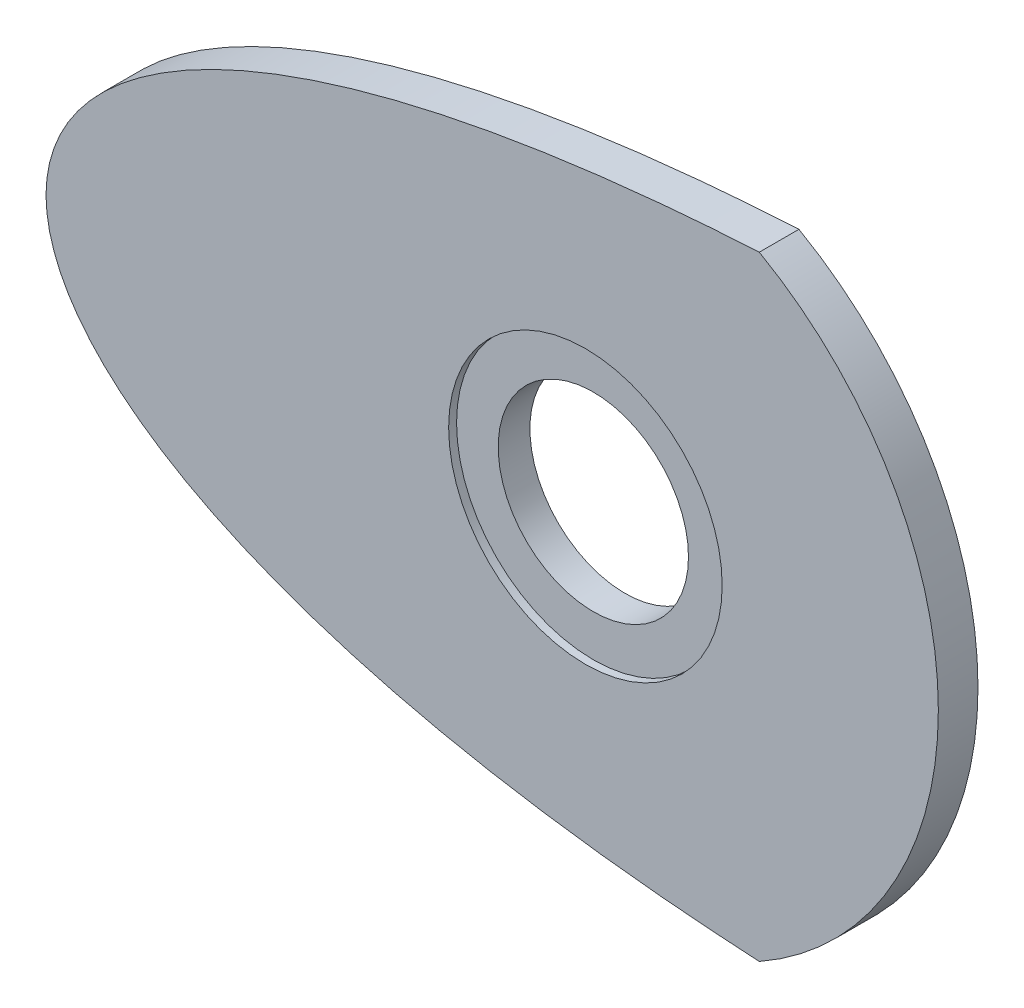
from build123d import *

# Parameters (mm, degrees)
BOSS_EXTRUDE2_DEPTH = 2.54
SKETCH1_5_R         = 4.233333332
BOSS_EXTRUDE3_DEPTH = 7.62
SKETCH1_6_R         = 6.096
CUT_EXTRUDE1_DEPTH  = 179.814895395
SKETCH4_R           = 8.763
CUT_EXTRUDE2_DEPTH  = 0.508


with BuildPart() as part:
    # Sketch1 → Boss-Extrude2 (new body)
    with BuildSketch(Plane.XY):
        with BuildLine():
            ThreePointArc((-126.772670279, 7.21547203), (-115.299991188, 26.89475243), (-126.772670279, 46.57403283))
            add(Edge.make_bspline(
                [(-172.474815081, 26.89475243), (-172.473819891, 27.230973869), (-172.419747256, 28.067223274), (-172.09778315, 29.537851691), (-171.305841422, 31.369969831), (-169.889362805, 33.399100842), (-167.799877065, 35.466403756), (-165.058549528, 37.462309128), (-161.711634876, 39.321499724), (-157.809164116, 41.006194136), (-153.398533523, 42.494070588), (-148.523738699, 43.77188575), (-143.225981342, 44.832188047), (-137.544438785, 45.671493001), (-132.01714462, 46.238870937), (-128.386674126, 46.485977046), (-126.772670279, 46.57403283)],
                knots=[0.5, 0.5, 0.5, 0.5, 0.502166769, 0.505390167, 0.509655974, 0.514947682, 0.521244711, 0.528520886, 0.536744945, 0.54588136, 0.555890751, 0.566730119, 0.57835299, 0.590709588, 0.603747039, 0.614168613, 0.614168613, 0.614168613, 0.614168613], degree=3))
            add(Edge.make_bspline(
                [(-172.474815081, 26.89475243), (-172.473819891, 26.558530991), (-172.419747256, 25.722281586), (-172.09778315, 24.251653169), (-171.305841422, 22.419535029), (-169.889362805, 20.390404018), (-167.799877065, 18.323101104), (-165.058549527, 16.327195732), (-161.711634875, 14.468005136), (-157.809164116, 12.783310723), (-153.398533522, 11.295434272), (-148.523738698, 10.01761911), (-143.225981341, 8.957316813), (-137.544438784, 8.118011859), (-132.01714462, 7.550633923), (-128.386674126, 7.303527814), (-126.772670279, 7.21547203)],
                knots=[0.5, 0.5, 0.5, 0.5, 0.502166769, 0.505390167, 0.509655974, 0.514947682, 0.521244711, 0.528520886, 0.536744945, 0.54588136, 0.555890751, 0.566730119, 0.57835299, 0.590709588, 0.603747039, 0.614168613, 0.614168613, 0.614168613, 0.614168613], degree=3))
        make_face()
    extrude(amount=BOSS_EXTRUDE2_DEPTH)

    # Sketch1_5 → Boss-Extrude3 (add)
    with BuildSketch(Plane.XY):
        with Locations((-159.081098581, 26.89475243)):
            Circle(SKETCH1_5_R)
    extrude(amount=-BOSS_EXTRUDE3_DEPTH)

    # Sketch1_6 → Cut-Extrude1 (cut, through all)
    with BuildSketch(Plane.XY):
        with Locations((-137.914431916, 26.89475243)):
            Circle(SKETCH1_6_R)
    extrude(amount=CUT_EXTRUDE1_DEPTH, mode=Mode.SUBTRACT)

    # Sketch4 → Cut-Extrude2 (cut)
    with BuildSketch(Plane.XY.offset(2.54)):
        with Locations((-137.914431916, 26.89475243)):
            Circle(SKETCH4_R)
    extrude(amount=-CUT_EXTRUDE2_DEPTH, mode=Mode.SUBTRACT)


solid = part.part
